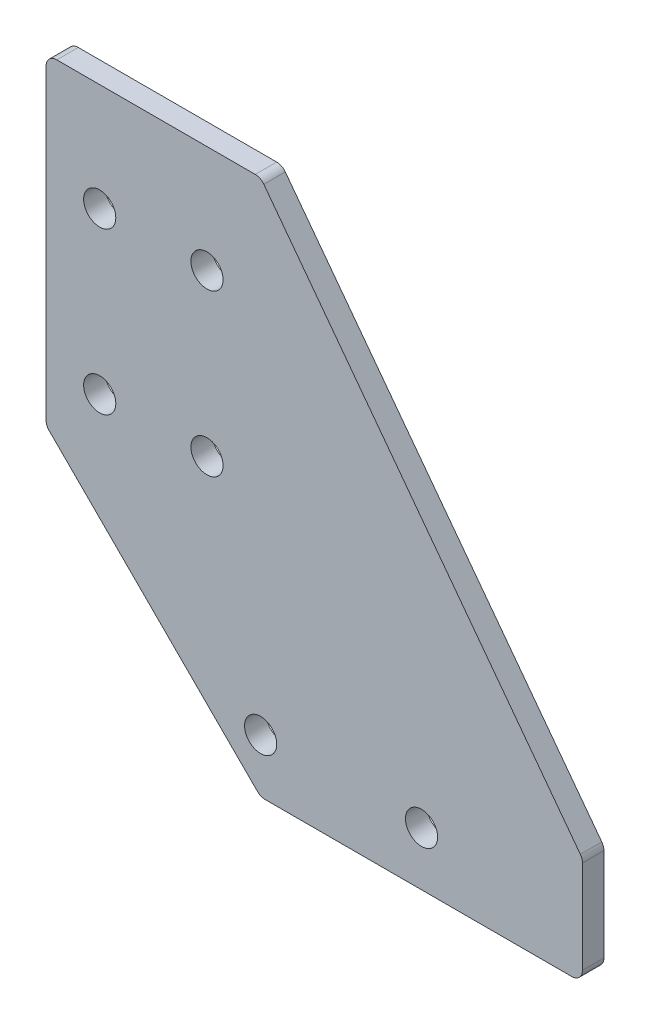
from build123d import *

# Parameters (mm, degrees)
SKETCH_1_R      = 1.5
EXTRUDE_1_DEPTH = 2
FILLET_1_R      = 1


with BuildPart() as part:
    # 草图1 → 凸台-拉伸1 (new body)
    with BuildSketch(Plane.XY):
        Polygon((-5, 45), (15, 45), (45, 5), (45, -5), (15, -5), (-5, 15), align=None)
        with Locations((0, 35)):
            Circle(SKETCH_1_R, mode=Mode.SUBTRACT)
        with Locations((30, 0)):
            Circle(SKETCH_1_R, mode=Mode.SUBTRACT)
        with Locations((0, 20)):
            Circle(SKETCH_1_R, mode=Mode.SUBTRACT)
        with Locations((15, 0)):
            Circle(SKETCH_1_R, mode=Mode.SUBTRACT)
        with Locations((10, 35)):
            Circle(SKETCH_1_R, mode=Mode.SUBTRACT)
        with Locations((10, 20)):
            Circle(SKETCH_1_R, mode=Mode.SUBTRACT)
    extrude(amount=EXTRUDE_1_DEPTH)

    # 圆角1
    fillet_1_edges = [part.edges().sort_by_distance(p)[0] for p in [
        (-5, 45, 1),
        (15, 45, 1),
        (45, 5, 1),
        (45, -5, 1),
        (15, -5, 1),
        (-5, 15, 1),
    ]]
    fillet(fillet_1_edges, radius=FILLET_1_R)


solid = part.part
